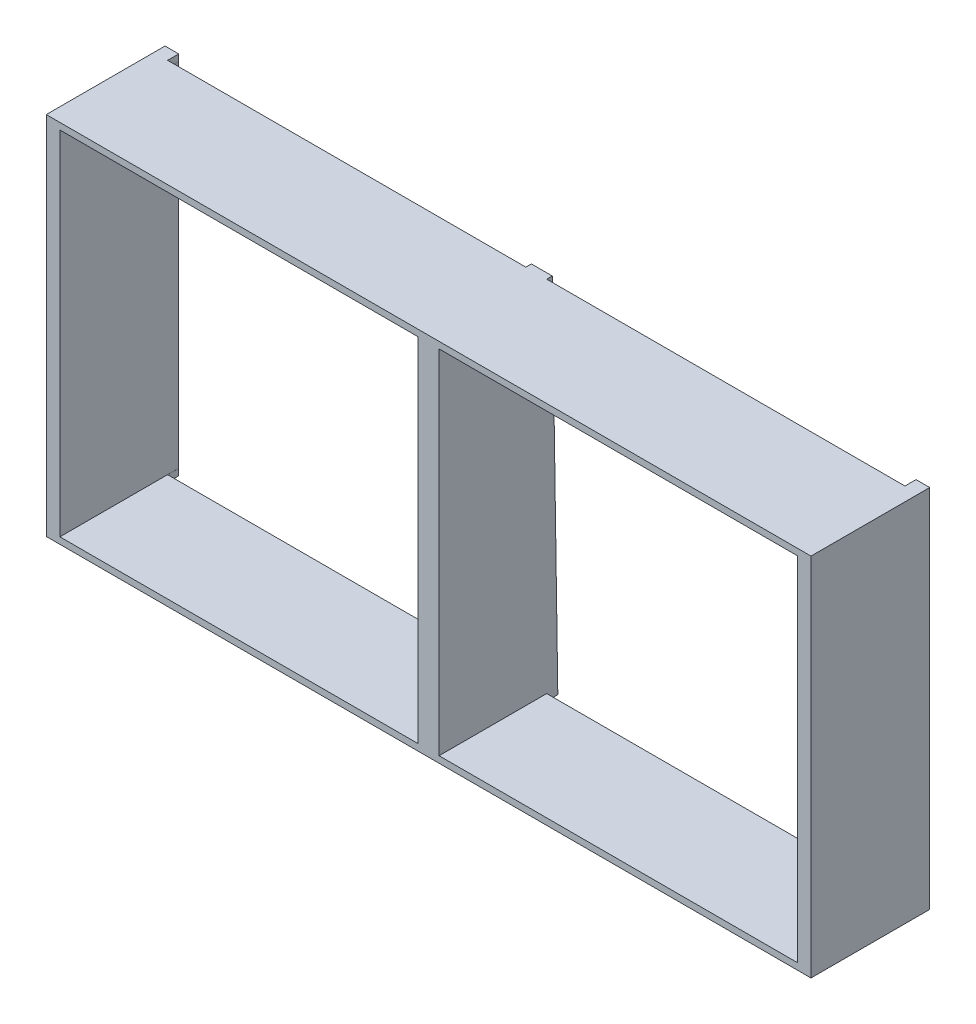
from build123d import *

# Parameters (mm, degrees)
SKETCH_1_W          = 5860
SKETCH_1_H          = 2800
SKETCH_1_W_2        = 2745.357142857
SKETCH_1_H_2        = 2700
EXTRUDE_1_DEPTH     = 910
SKETCH_2_W          = 2745
SKETCH_2_H          = 85
CUT_EXTRUDE_1_DEPTH = 2801
CUT_EXTRUDE_2_DEPTH = 160


with BuildPart() as part:
    # Эскиз1 → Бобышка-Вытянуть1 (new body)
    with BuildSketch(Plane.XY):
        Rectangle(SKETCH_1_W, SKETCH_1_H)
        with Locations((-1452.678571429, 0)):
            Rectangle(SKETCH_1_W_2, SKETCH_1_H_2, mode=Mode.SUBTRACT)
        with Locations((1452.678571429, 0)):
            Rectangle(SKETCH_1_W_2, SKETCH_1_H_2, mode=Mode.SUBTRACT)
    extrude(amount=EXTRUDE_1_DEPTH)

    # Эскиз2 → Вырез-Вытянуть1 (cut, through all)
    with BuildSketch(Plane.XZ.offset(1400)):
        with Locations((-1452.5, 42.5)):
            Rectangle(SKETCH_2_W, SKETCH_2_H)
        with Locations((1452.5, 42.5)):
            Rectangle(SKETCH_2_W, SKETCH_2_H)
    extrude(amount=-CUT_EXTRUDE_1_DEPTH, mode=Mode.SUBTRACT)

    # Эскиз3 → Вырез-Вытянуть2 (cut)
    with BuildSketch(Plane.ZY.offset(80)):
        Polygon((0, 1400), (0, -1400), (42.5, 1400), align=None)
    extrude(amount=-CUT_EXTRUDE_2_DEPTH, mode=Mode.SUBTRACT)


solid = part.part
